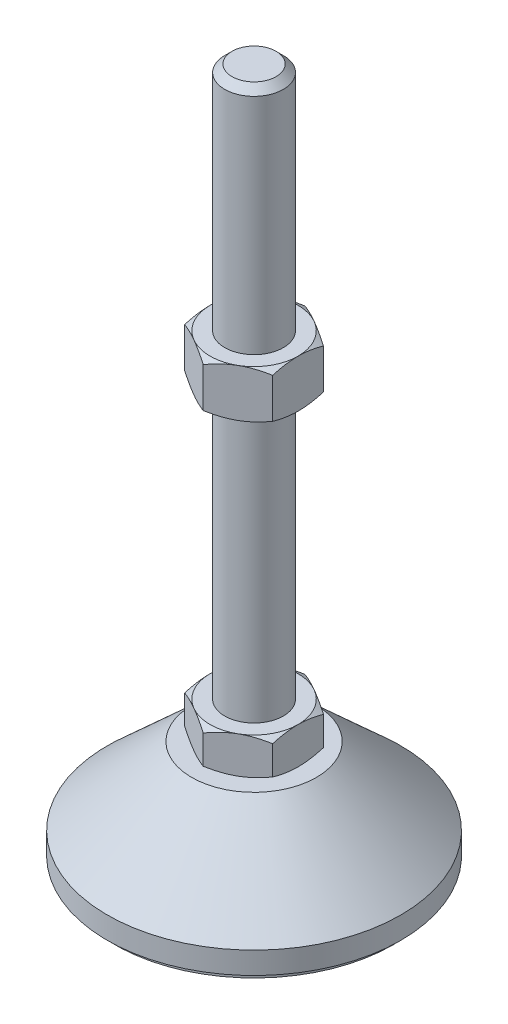
from build123d import *

# Parameters (mm, degrees)
EXTRUDE_1_DEPTH = 10
EXTRUDE_2_DEPTH = 13


with BuildPart() as part:
    # Эскиз1 → Повернуть1 (revolve)
    with BuildSketch(Plane.XY, mode=Mode.PRIVATE) as revolve_1_sk:
        Polygon((0, 0), (-38, 0), (-38, 2), (-40, 2), (-40, 8), (-17, 29), (-8, 29), (-8, 39), (-8, 187), (-6, 189), (0, 189), align=None)
    revolve(revolve_1_sk.sketch.rotate(Axis((0, 0, 0), (0, 1, 0)), 180), axis=Axis((0, 0, 0), (0, 1, 0)))  # turned: the seam where the file's is

    # Эскиз2 → Бобышка-Вытянуть1 (add)
    with BuildSketch(Plane(origin=(0, 29, 0), x_dir=(1, 0, 0), z_dir=(0, 1, 0))):
        Polygon((0, 13.856406461), (-12, 6.92820323), (-12, -6.92820323), (0, -13.856406461), (12, -6.92820323), (12, 6.92820323), align=None)
    extrude(amount=EXTRUDE_1_DEPTH)

    # Эскиз3 → Бобышка-Вытянуть2 (add)
    with BuildSketch(Plane(origin=(0, 113, 0), x_dir=(1, 0, 0), z_dir=(0, 1, 0))):
        Polygon((12, 6.92820323), (0, 13.856406461), (-12, 6.92820323), (-12, -6.92820323), (0, -13.856406461), (12, -6.92820323), align=None)
    extrude(amount=EXTRUDE_2_DEPTH)

    # Эскиз4 → Вырез-Повернуть2 (revolve, cut)
    with BuildSketch(Plane.XY, mode=Mode.PRIVATE) as cut_revolve_2_sk:
        Polygon((-23.258330249, 126), (-12, 126), (-23.258330249, 119.5), align=None)
        Polygon((-23.258330249, 113), (-23.258330249, 119.5), (-12, 113), align=None)
        Polygon((-20.660254038, 39), (-20.660254038, 34), (-12, 39), align=None)
        Polygon((-20.660254038, 34), (-20.660254038, 29), (-12, 29), align=None)
    revolve(cut_revolve_2_sk.sketch.rotate(Axis((0, 189, 0), (0, -1, 0)), 180), axis=Axis((0, 189, 0), (0, -1, 0)), mode=Mode.SUBTRACT)  # turned: the seam where the file's is


solid = part.part
